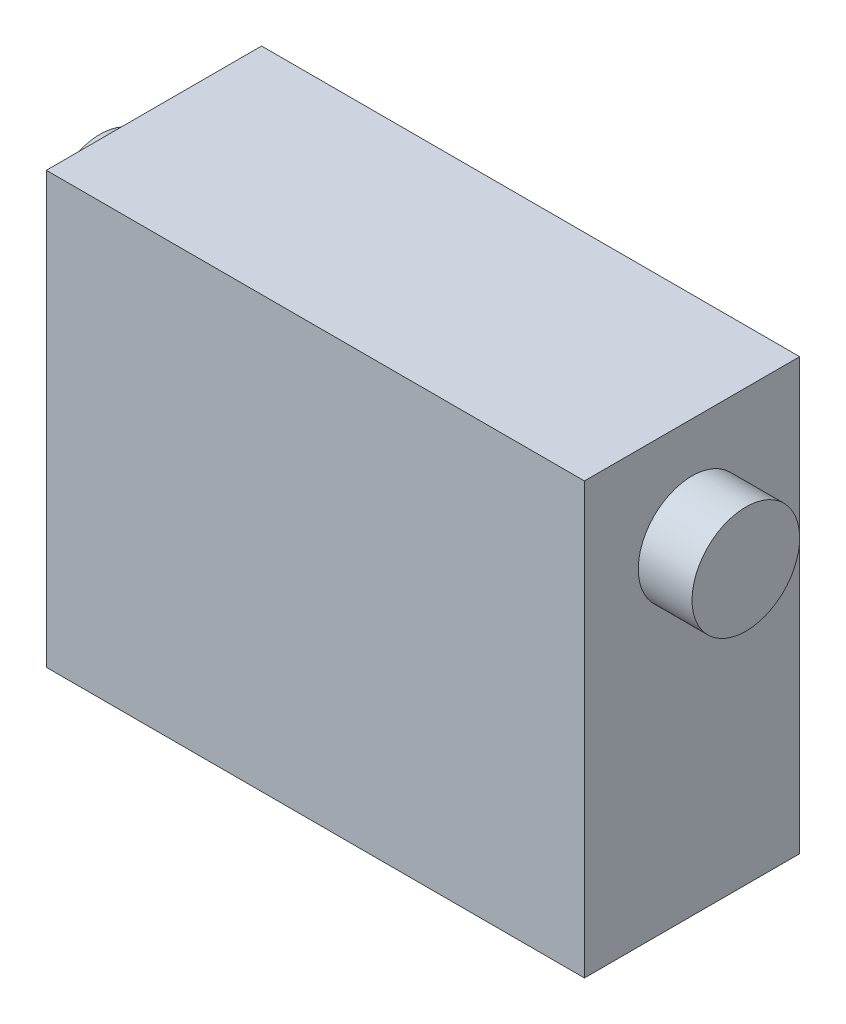
from build123d import *

# Parameters (mm, degrees)
SKETCH1_W                = 50
SKETCH1_H                = 40
BOSS_EXTRUDE1_DEPTH      = 20
SKETCH2_R                = 5
BOSS_EXTRUDE2_DEPTH      = 5
BOSS_EXTRUDE2_DEPTH_BACK = 55


with BuildPart() as part:
    # Sketch1 → Boss-Extrude1 (new body)
    with BuildSketch(Plane.XY):
        Rectangle(SKETCH1_W, SKETCH1_H)
    extrude(amount=BOSS_EXTRUDE1_DEPTH)

    # Sketch2 → Boss-Extrude2 (add, two sides)
    with BuildSketch(Plane.ZY.offset(25)) as boss_extrude2_sk:
        with Locations((10, 10.407747154)):
            Circle(SKETCH2_R)
    extrude(amount=BOSS_EXTRUDE2_DEPTH)
    extrude(boss_extrude2_sk.sketch, amount=-BOSS_EXTRUDE2_DEPTH_BACK)


solid = part.part
